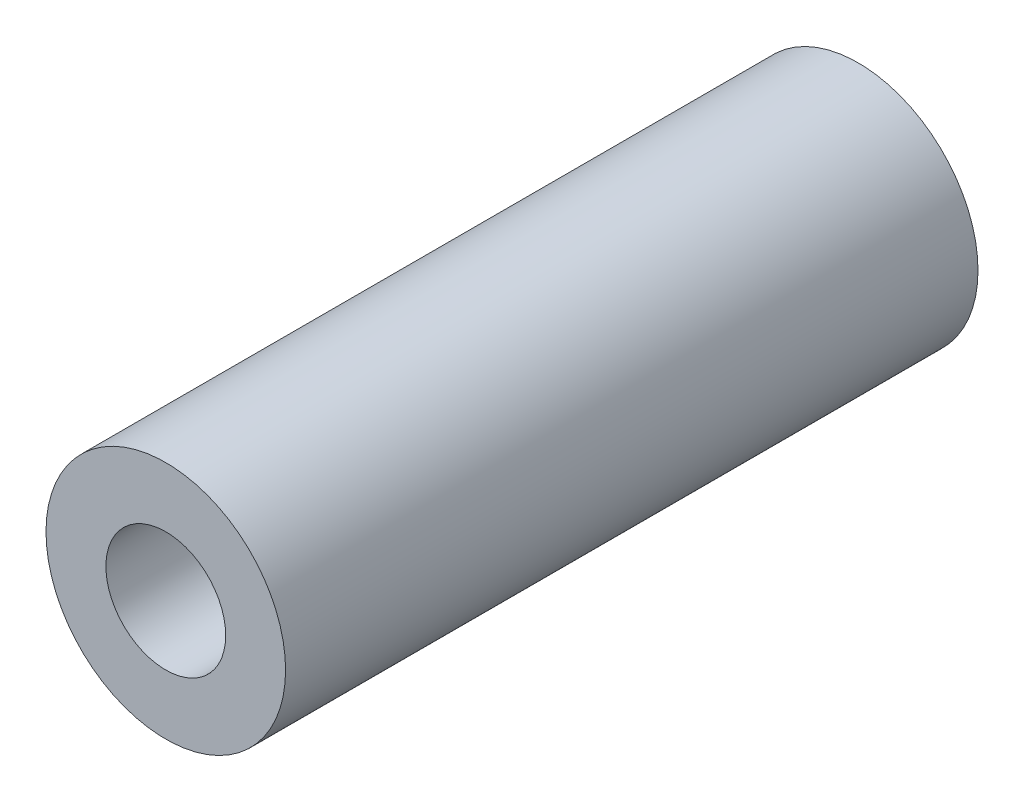
from build123d import *

# Parameters (mm, degrees)
SKETCH1_R                 = 5
BOSS_EXTRUDE1_DEPTH       = 28.9
F_5_0MM_DOWEL_HOLE1_D     = 5
F_5_0MM_DOWEL_HOLE1_DEPTH = 28.9


with BuildPart() as part:
    # Sketch1 → Boss-Extrude1 (new body)
    with BuildSketch(Plane.XY):
        Circle(SKETCH1_R)
    extrude(amount=BOSS_EXTRUDE1_DEPTH)

    # Ø5.0mm Dowel Hole1
    with Locations(Plane.XY.offset(28.9)):
        with Locations((0, 0)):
            Hole(F_5_0MM_DOWEL_HOLE1_D / 2, depth=F_5_0MM_DOWEL_HOLE1_DEPTH)


solid = part.part
